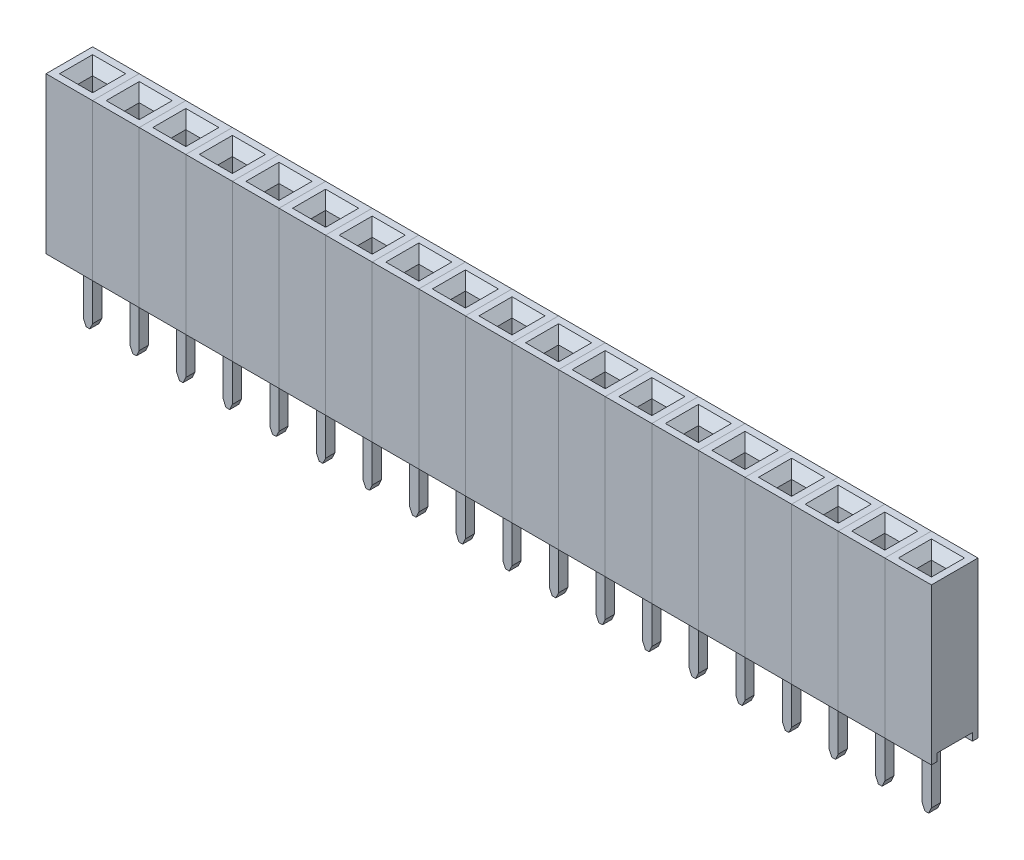
from build123d import *

# Parameters (mm, degrees)
SKETCH1_W               = 2.54
SKETCH1_H               = 8.5
BOSS_EXTRUDE1_DEPTH     = 1.27
SKETCH2_W               = 1.94
SKETCH2_H               = 0.410374384
CUT_EXTRUDE1_DEPTH      = 50
SKETCH4_W               = 0.8
SKETCH4_H               = 0.8
CUT_EXTRUDE2_DEPTH      = 1.5
CHAMFER1_SIZE           = 0.5
CUT_EXTRUDE3_DEPTH      = 3
CUT_EXTRUDE3_DEPTH_BACK = 3
SKETCH5_W               = 1.8
SKETCH5_H               = 1.8
BOSS_EXTRUDE4_DEPTH     = 0.85
BOSS_EXTRUDE5_DEPTH     = 0.25
LPATTERN1_COUNT         = 19
LPATTERN1_PITCH         = 2.54


with BuildPart() as part:
    # Sketch1 → Boss-Extrude1 (new, symmetric)
    with BuildSketch(Plane.XY):
        Rectangle(SKETCH1_W, SKETCH1_H)
    extrude(amount=BOSS_EXTRUDE1_DEPTH, both=True)

    # Sketch2 → Cut-Extrude1 (cut, symmetric)
    with BuildSketch(Plane(origin=(0, 0, 0), x_dir=(0, 0, -1), z_dir=(1, 0, 0))):
        with Locations((0, -4.044812808)):
            Rectangle(SKETCH2_W, SKETCH2_H)
    extrude(amount=CUT_EXTRUDE1_DEPTH, both=True, mode=Mode.SUBTRACT)

    # Sketch4 → Cut-Extrude2 (cut)
    with BuildSketch(Plane(origin=(0, 4.25, 0), x_dir=(1, 0, 0), z_dir=(0, 1, 0))):
        Rectangle(SKETCH4_W, SKETCH4_H)
    extrude(amount=-CUT_EXTRUDE2_DEPTH, mode=Mode.SUBTRACT)

    # Chamfer1
    chamfer1_edges = [part.edges().sort_by_distance(p)[0] for p in [
        (0, 4.25, -0.4),
        (-0.4, 4.25, 0),
        (0, 4.25, 0.4),
        (0.4, 4.25, 0),
    ]]
    chamfer(chamfer1_edges, length=CHAMFER1_SIZE)

    # Sketch5 → Cut-Extrude3 (cut, two sides: drawn at the far end of the back side and taken through both)
    with BuildSketch(Plane(origin=(0, 0, 0), x_dir=(1, 0, 0), z_dir=(0, 1, 0)).offset(-CUT_EXTRUDE3_DEPTH_BACK)):
        Rectangle(SKETCH5_W, SKETCH5_H)
    extrude(amount=CUT_EXTRUDE3_DEPTH + CUT_EXTRUDE3_DEPTH_BACK, mode=Mode.SUBTRACT)

    # Sketch9 → Boss-Extrude4 (add, symmetric)
    with BuildSketch(Plane.XY):
        with BuildLine():
            Line((0.852765845, -2.693306042), (0.852765845, -1.341648528))
            Line((0.852765845, -1.341648528), (0.602186386, -1.260876719))
            Line((0.602186386, -1.260876719), (0.413271806, 1.491878581))
            ThreePointArc((0.413271806, 1.491878581), (0.162585139, 1.576117793), (0.280281264, 1.339289432))
            Line((0.280281264, 1.339289432), (0.507505583, -1.97169351))
            ThreePointArc((0.507505583, -1.97169351), (0.361743925, -2.312679398), (0, -2.394283131))
            ThreePointArc((0, -2.394283131), (-0.361743925, -2.312679398), (-0.507505583, -1.97169351))
            Line((-0.507505583, -1.97169351), (-0.280281264, 1.339289432))
            ThreePointArc((-0.280281264, 1.339289432), (-0.162585139, 1.576117793), (-0.413271806, 1.491878581))
            Line((-0.413271806, 1.491878581), (-0.602186386, -1.260876719))
            Line((-0.602186386, -1.260876719), (-0.852765845, -1.341648528))
            Line((-0.852765845, -1.341648528), (-0.852765845, -2.693306042))
            Line((-0.852765845, -2.693306042), (-0.280728289, -3.053320584))
            Line((-0.280728289, -3.053320584), (-0.25, -3.053320584))
            Line((-0.25, -3.053320584), (0.25, -3.053320584))
            Line((0.25, -3.053320584), (0.280728289, -3.053320584))
            Line((0.280728289, -3.053320584), (0.852765845, -2.693306042))
        make_face()
    extrude(amount=BOSS_EXTRUDE4_DEPTH, both=True)

    # Sketch9_3 → Boss-Extrude5 (add, symmetric)
    with BuildSketch(Plane.XY):
        Polygon((0.25, -7.299491593), (0.25, -3.053320584), (-0.25, -3.053320584), (-0.25, -7.299491593), (-0.1, -7.621167632), (0.1, -7.621167632), align=None)
    extrude(amount=BOSS_EXTRUDE5_DEPTH, both=True)


with BuildPart() as lpattern1_1:
    # LPattern1: pattern copy
    add(part.part.moved(Location(Vector(-1, 0, 0) * (1 * LPATTERN1_PITCH))))


with BuildPart() as lpattern1_2:
    # LPattern1: pattern copy
    add(part.part.moved(Location(Vector(-1, 0, 0) * (2 * LPATTERN1_PITCH))))


with BuildPart() as lpattern1_3:
    # LPattern1: pattern copy
    add(part.part.moved(Location(Vector(-1, 0, 0) * (3 * LPATTERN1_PITCH))))


with BuildPart() as lpattern1_4:
    # LPattern1: pattern copy
    add(part.part.moved(Location(Vector(-1, 0, 0) * (4 * LPATTERN1_PITCH))))


with BuildPart() as lpattern1_5:
    # LPattern1: pattern copy
    add(part.part.moved(Location(Vector(-1, 0, 0) * (5 * LPATTERN1_PITCH))))


with BuildPart() as lpattern1_6:
    # LPattern1: pattern copy
    add(part.part.moved(Location(Vector(-1, 0, 0) * (6 * LPATTERN1_PITCH))))


with BuildPart() as lpattern1_7:
    # LPattern1: pattern copy
    add(part.part.moved(Location(Vector(-1, 0, 0) * (7 * LPATTERN1_PITCH))))


with BuildPart() as lpattern1_8:
    # LPattern1: pattern copy
    add(part.part.moved(Location(Vector(-1, 0, 0) * (8 * LPATTERN1_PITCH))))


with BuildPart() as lpattern1_9:
    # LPattern1: pattern copy
    add(part.part.moved(Location(Vector(-1, 0, 0) * (9 * LPATTERN1_PITCH))))


with BuildPart() as lpattern1_10:
    # LPattern1: pattern copy
    add(part.part.moved(Location(Vector(-1, 0, 0) * (10 * LPATTERN1_PITCH))))


with BuildPart() as lpattern1_11:
    # LPattern1: pattern copy
    add(part.part.moved(Location(Vector(-1, 0, 0) * (11 * LPATTERN1_PITCH))))


with BuildPart() as lpattern1_12:
    # LPattern1: pattern copy
    add(part.part.moved(Location(Vector(-1, 0, 0) * (12 * LPATTERN1_PITCH))))


with BuildPart() as lpattern1_13:
    # LPattern1: pattern copy
    add(part.part.moved(Location(Vector(-1, 0, 0) * (13 * LPATTERN1_PITCH))))


with BuildPart() as lpattern1_14:
    # LPattern1: pattern copy
    add(part.part.moved(Location(Vector(-1, 0, 0) * (14 * LPATTERN1_PITCH))))


with BuildPart() as lpattern1_15:
    # LPattern1: pattern copy
    add(part.part.moved(Location(Vector(-1, 0, 0) * (15 * LPATTERN1_PITCH))))


with BuildPart() as lpattern1_16:
    # LPattern1: pattern copy
    add(part.part.moved(Location(Vector(-1, 0, 0) * (16 * LPATTERN1_PITCH))))


with BuildPart() as lpattern1_17:
    # LPattern1: pattern copy
    add(part.part.moved(Location(Vector(-1, 0, 0) * (17 * LPATTERN1_PITCH))))


with BuildPart() as lpattern1_18:
    # LPattern1: pattern copy
    add(part.part.moved(Location(Vector(-1, 0, 0) * (18 * LPATTERN1_PITCH))))


solid = Compound([part.part, lpattern1_1.part, lpattern1_2.part, lpattern1_3.part, lpattern1_4.part, lpattern1_5.part, lpattern1_6.part, lpattern1_7.part, lpattern1_8.part, lpattern1_9.part, lpattern1_10.part, lpattern1_11.part, lpattern1_12.part, lpattern1_13.part, lpattern1_14.part, lpattern1_15.part, lpattern1_16.part, lpattern1_17.part, lpattern1_18.part])
